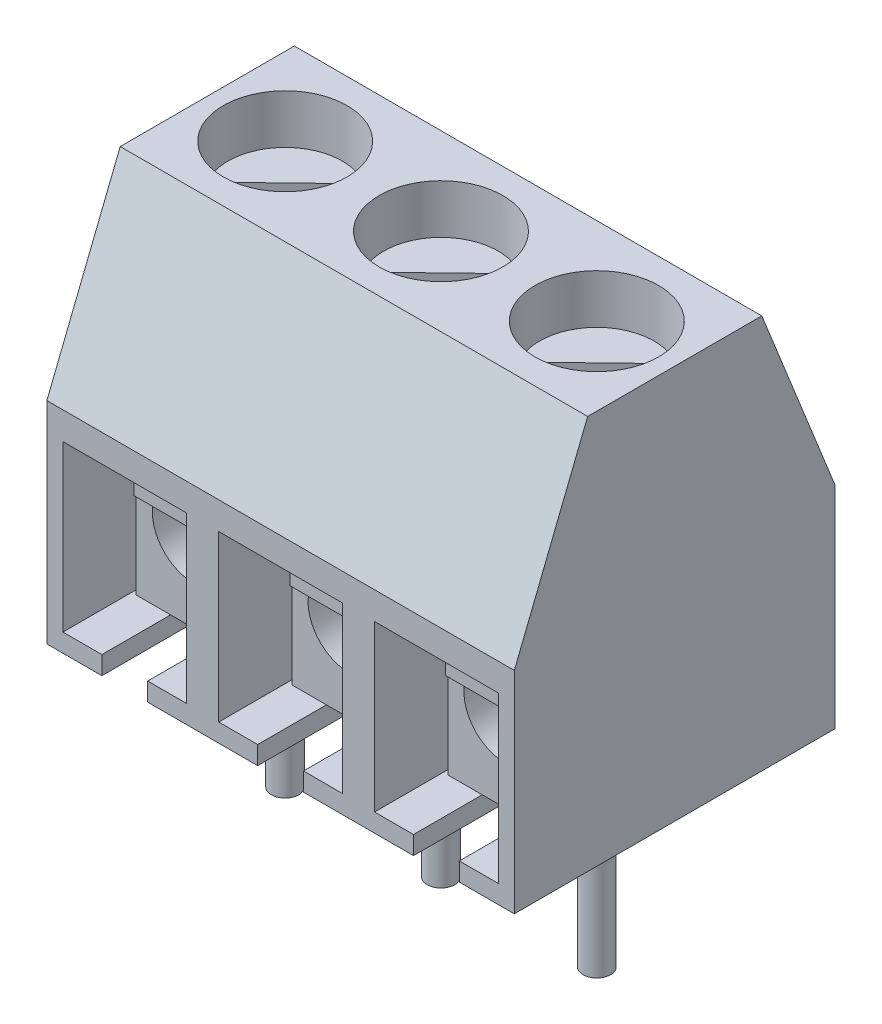
from build123d import *

# Parameters (mm, degrees)
BOSS_EXTRU_1_DEPTH         = 3.4
ENL_V_MAT_EXTRU_1_DEPTH    = 6
ESQUISSE3_R                = 1.35
ENL_V_MAT_EXTRU_2_DEPTH    = 4.6
BOSS_EXTRU_2_START         = -1
ESQUISSE4_R                = 1.25
BOSS_EXTRU_2_DEPTH         = 3.4
ENL_V_MAT_EXTRU_3_DEPTH    = 0.4
BOSS_EXTRU_3_START         = -1.5
ESQUISSE6_R                = 0.9
BOSS_EXTRU_3_DEPTH         = 4.5
ESQUISSE7_R                = 0.3
BOSS_EXTRU_4_DEPTH         = 4
EXTRU_MINCE1_DEPTH         = 0.7
R_P_TITION_LIN_AIRE2_COUNT = 3
R_P_TITION_LIN_AIRE2_PITCH = 3.4
R_P_TITION_LIN_AIRE3_COUNT = 3
R_P_TITION_LIN_AIRE3_PITCH = 3.4


with BuildPart() as part:
    # Esquisse1 → Boss.-Extru.1 (new body)
    with BuildSketch(Plane(origin=(0, 0, 0), x_dir=(0, 0, -1), z_dir=(1, 0, 0))):
        Polygon((0, 0), (0, 4.6), (1.6, 8.6), (5.4, 8.6), (7, 4.6), (7, 0), align=None)
    boss_extru_1 = extrude(amount=BOSS_EXTRU_1_DEPTH)

    # Esquisse2 → Enlèv. mat.-Extru.1 (cut)
    with BuildSketch(Plane.XY):
        Polygon((0.35, 0.4), (1.2, 0.4), (1.2, 0), (2.2, 0), (2.2, 0.4), (3.05, 0.4), (3.05, 4), (0.35, 4), align=None)
    enl_v_mat_extru_1 = extrude(amount=-ENL_V_MAT_EXTRU_1_DEPTH, mode=Mode.SUBTRACT)

    # Esquisse3 → Enlèv. mat.-Extru.2 (cut)
    with BuildSketch(Plane(origin=(0, 8.6, 0), x_dir=(1, 0, 0), z_dir=(0, 1, 0))):
        with Locations((1.7, 3.5)):
            Circle(ESQUISSE3_R)
    enl_v_mat_extru_2 = extrude(amount=-ENL_V_MAT_EXTRU_2_DEPTH, mode=Mode.SUBTRACT)

    # Répétition linéaire2: Boss.-Extru.1, Enlèv. mat.-Extru.1, Enlèv. mat.-Extru.2 ×3
    with Locations(*[(i * R_P_TITION_LIN_AIRE2_PITCH, 0, 0) for i in range(1, R_P_TITION_LIN_AIRE2_COUNT)]):
        add(boss_extru_1)
        add(enl_v_mat_extru_1, mode=Mode.SUBTRACT)
        add(enl_v_mat_extru_2, mode=Mode.SUBTRACT)


with BuildPart() as body_2:
    # Esquisse4 → Boss.-Extru.2 (new body)
    with BuildSketch(Plane(origin=(0, 8.6, 0), x_dir=(1, 0, 0), z_dir=(0, 1, 0)).offset(BOSS_EXTRU_2_START)):
        with Locations((1.7, 3.5)):
            Circle(ESQUISSE4_R)
    extrude(amount=-BOSS_EXTRU_2_DEPTH)

    # Esquisse5 → Enlèv. mat.-Extru.3 (cut)
    with BuildSketch(Plane(origin=(0, 7.6, 0), x_dir=(1, 0, 0), z_dir=(0, 1, 0))):
        with BuildLine():
            Line((0.61870802, 2.87285755), (2.364496958, 4.558746331))
            ThreePointArc((2.364496958, 4.558746331), (2.59917475, 4.368322963), (2.78129198, 4.12714245))
            Line((2.78129198, 4.12714245), (1.035503042, 2.441253669))
            ThreePointArc((1.035503042, 2.441253669), (0.80082525, 2.631677037), (0.61870802, 2.87285755))
        make_face()
    extrude(amount=-ENL_V_MAT_EXTRU_3_DEPTH, mode=Mode.SUBTRACT)


with BuildPart() as body_3:
    # Esquisse6 → Boss.-Extru.3 (new body)
    with BuildSketch(Plane.XY.offset(BOSS_EXTRU_3_START)):
        Polygon((0.45, 0.4), (2.95, 0.4), (2.95, 3.9), (2.45, 3.9), (2.45, 3.65), (0.95, 3.65), (0.95, 3.9), (0.45, 3.9), align=None)
        with Locations((1.7, 2.15)):
            Circle(ESQUISSE6_R, mode=Mode.SUBTRACT)
    extrude(amount=-BOSS_EXTRU_3_DEPTH)

    # Esquisse7 → Boss.-Extru.4 (add)
    with BuildSketch(Plane.XZ.offset(-0.4)):
        with Locations((1.7, -3.5)):
            Circle(ESQUISSE7_R)
    extrude(amount=BOSS_EXTRU_4_DEPTH)


with BuildPart() as body_4:
    # Esquisse8 → Extru.-Mince1 (new body, symmetric)
    with BuildSketch(Plane(origin=(1.7, 0, 0), x_dir=(0, 0, -1), z_dir=(1, 0, 0))):
        with BuildLine():
            Line((2.15, 3.9), (1.5, 3.9))
            ThreePointArc((1.5, 3.9), (1.075735931, 3.724264069), (0.9, 3.3))
            Line((0.9, 3.3), (0.9, 2.853369234))
            Line((0.9, 2.853369234), (2.391205681, 1.602099097))
            Line((2.391205681, 1.602099097), (2.519763203, 1.755307986))
            Line((2.519763203, 1.755307986), (1.1, 2.946630766))
            Line((1.1, 2.946630766), (1.1, 3.3))
            ThreePointArc((1.1, 3.3), (1.217157288, 3.582842712), (1.5, 3.7))
            Line((1.5, 3.7), (2.15, 3.7))
            Line((2.15, 3.7), (2.15, 3.9))
        make_face()
    extrude(amount=EXTRU_MINCE1_DEPTH, both=True)


with BuildPart() as r_p_tition_lin_aire3_1:
    # Répétition linéaire3: pattern copy
    add(body_3.part.moved(Location(Vector(1, 0, 0) * (1 * R_P_TITION_LIN_AIRE3_PITCH))))


with BuildPart() as r_p_tition_lin_aire3_2:
    # Répétition linéaire3: pattern copy
    add(body_3.part.moved(Location(Vector(1, 0, 0) * (2 * R_P_TITION_LIN_AIRE3_PITCH))))


with BuildPart() as r_p_tition_lin_aire3_3:
    # Répétition linéaire3: pattern copy
    add(body_4.part.moved(Location(Vector(1, 0, 0) * (1 * R_P_TITION_LIN_AIRE3_PITCH))))


with BuildPart() as r_p_tition_lin_aire3_4:
    # Répétition linéaire3: pattern copy
    add(body_4.part.moved(Location(Vector(1, 0, 0) * (2 * R_P_TITION_LIN_AIRE3_PITCH))))


with BuildPart() as r_p_tition_lin_aire3_5:
    # Répétition linéaire3: pattern copy
    add(body_2.part.moved(Location(Vector(1, 0, 0) * (1 * R_P_TITION_LIN_AIRE3_PITCH))))


with BuildPart() as r_p_tition_lin_aire3_6:
    # Répétition linéaire3: pattern copy
    add(body_2.part.moved(Location(Vector(1, 0, 0) * (2 * R_P_TITION_LIN_AIRE3_PITCH))))


solid = Compound([part.part, body_2.part, body_3.part, body_4.part, r_p_tition_lin_aire3_1.part, r_p_tition_lin_aire3_2.part, r_p_tition_lin_aire3_3.part, r_p_tition_lin_aire3_4.part, r_p_tition_lin_aire3_5.part, r_p_tition_lin_aire3_6.part])
